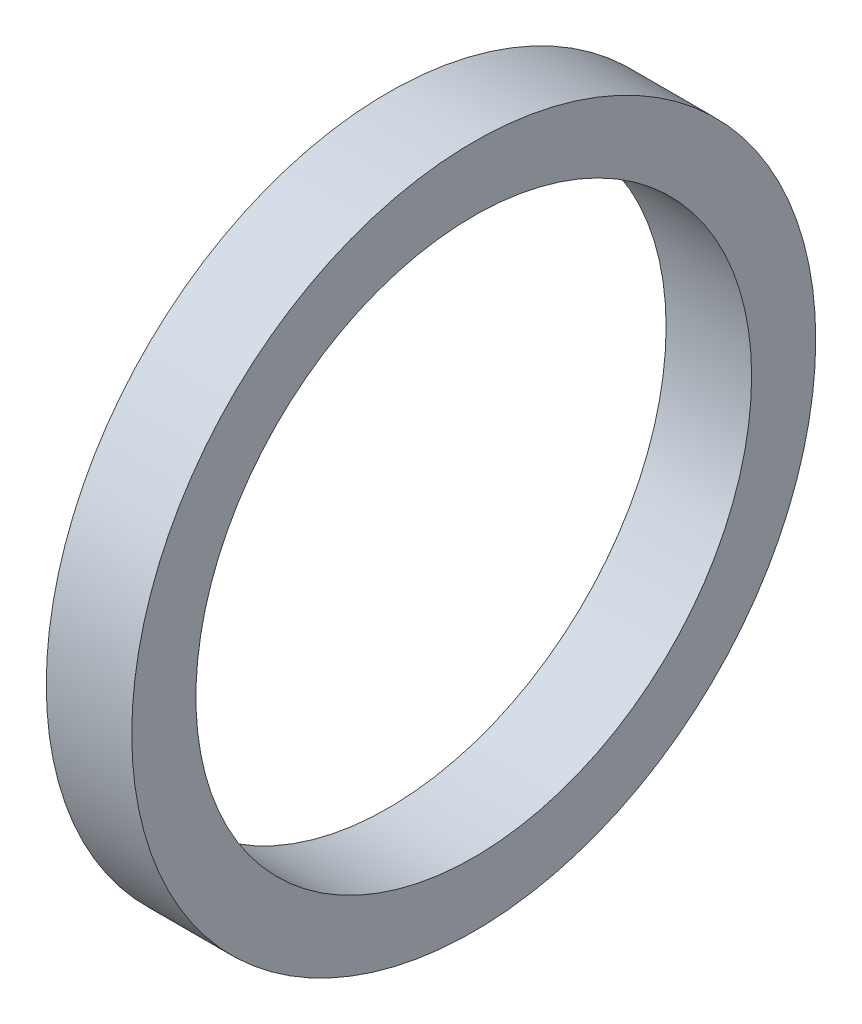
from build123d import *

# Parameters (mm, degrees)
SKETCH1_R           = 40
SKETCH1_R_2         = 32.5
BOSS_EXTRUDE1_DEPTH = 10


with BuildPart() as part:
    # Sketch1 → Boss-Extrude1 (new body)
    with BuildSketch(Plane(origin=(0, 0, 0), x_dir=(0, 0, -1), z_dir=(1, 0, 0))):
        Circle(SKETCH1_R)
        Circle(SKETCH1_R_2, mode=Mode.SUBTRACT)
    extrude(amount=BOSS_EXTRUDE1_DEPTH)


solid = part.part
